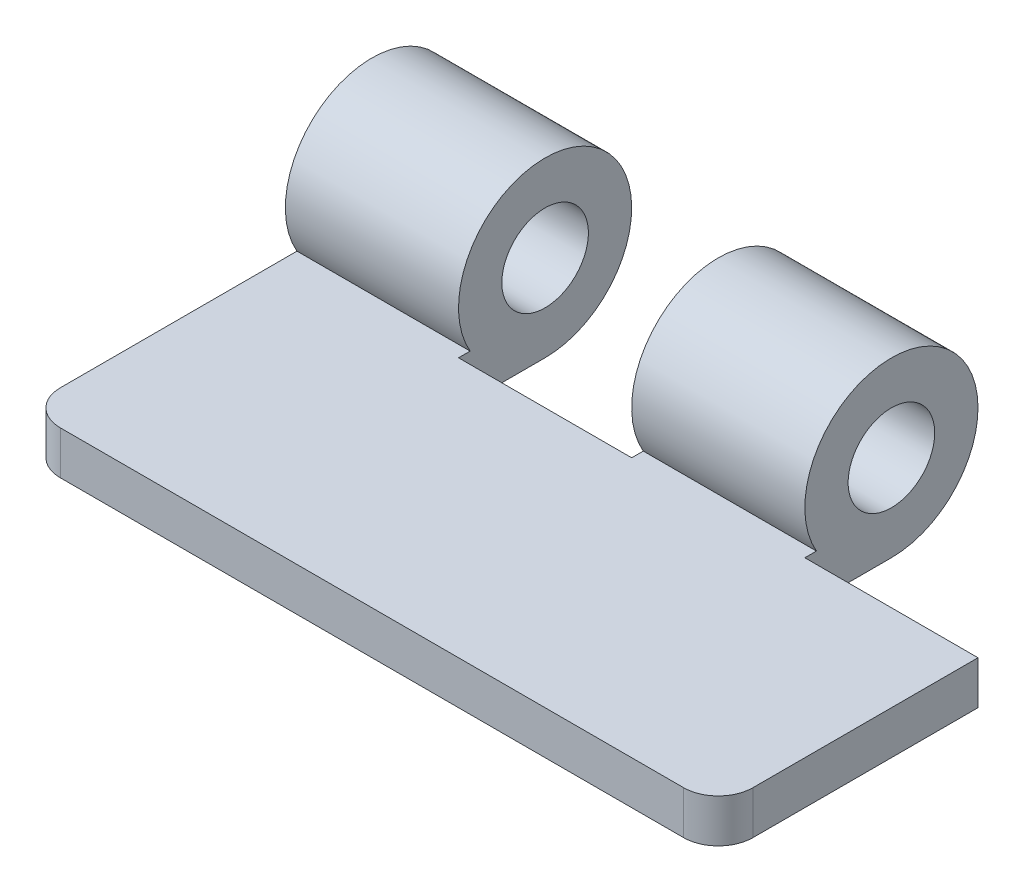
from build123d import *

# Parameters (mm, degrees)
BOSS_EXTRUDE1_DEPTH = 3.175
SKETCH2_R           = 6.35
SKETCH2_R_2         = 3.175
BOSS_EXTRUDE2_DEPTH = 12.7
FILLET1_R           = 2.54
SKETCH3_R           = 3.175
BOSS_EXTRUDE3_DEPTH = 12.7


with BuildPart() as part:
    # Sketch1 → Boss-Extrude1 (new body)
    with BuildSketch(Plane(origin=(0, 0, 0), x_dir=(1, 0, 0), z_dir=(0, 1, 0))):
        Polygon((0, 9.953217651), (-12.7, 9.953217651), (-12.7, 16.303217651), (-25.4, 16.303217651), (-25.4, 9.096782349), (-25.4, -9.096782349), (25.4, -9.096782349), (25.4, 9.953217651), (12.7, 9.953217651), (12.7, 16.303217651), (0, 16.303217651), align=None)
    extrude(amount=BOSS_EXTRUDE1_DEPTH)

    # Sketch2 → Boss-Extrude2 (add)
    with BuildSketch(Plane(origin=(0, 0, 0), x_dir=(0, 0, -1), z_dir=(1, 0, 0))):
        with Locations((16.303217651, 6.35)):
            Circle(SKETCH2_R)
        with Locations((16.303217651, 6.35)):
            Circle(SKETCH2_R_2, mode=Mode.SUBTRACT)
    extrude(amount=BOSS_EXTRUDE2_DEPTH)

    # Fillet1
    fillet1_edges = [part.edges().sort_by_distance(p)[0] for p in [
        (25.4, 1.5875, 9.096782349),
        (-25.4, 1.5875, 9.096782349),
    ]]
    fillet(fillet1_edges, radius=FILLET1_R)

    # Sketch3 → Boss-Extrude3 (add)
    with BuildSketch(Plane.ZY.offset(25.4)):
        with BuildLine():
            Line((-16.303217651, 0), (-9.953217651, 0))
            Line((-9.953217651, 0), (-9.953217651, 3.175))
            Line((-9.953217651, 3.175), (-10.803956337, 3.175))
            ThreePointArc((-10.803956337, 3.175), (-19.478217651, 11.849261314), (-16.303217651, 0))
        make_face()
        with Locations((-16.303217651, 6.35)):
            Circle(SKETCH3_R, mode=Mode.SUBTRACT)
    extrude(amount=-BOSS_EXTRUDE3_DEPTH)


solid = part.part
